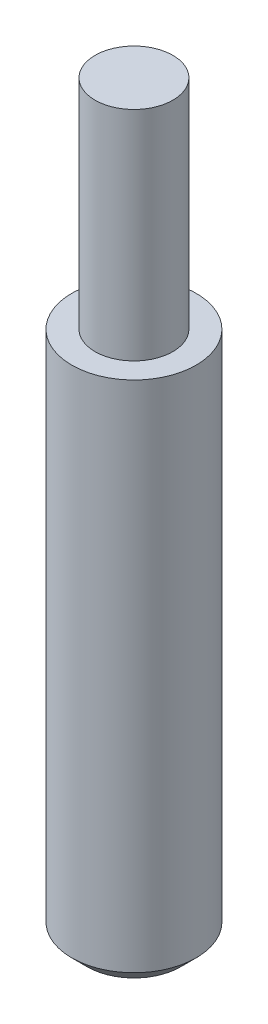
from build123d import *

# Parameters (mm, degrees)
SKETCH1_R           = 101.6
BOSS_EXTRUDE1_DEPTH = 1219.2
SKETCH2_OUTSIDE_W   = 455.722
SKETCH2_OUTSIDE_H   = 455.722
SKETCH2_OUTSIDE_R   = 63.5
CUT_EXTRUDE1_DEPTH  = 355.6
CHAMFER1_SIZE       = 25.4


with BuildPart() as part:
    # Sketch1 → Boss-Extrude1 (new body)
    with BuildSketch(Plane(origin=(0, 0, 0), x_dir=(1, 0, 0), z_dir=(0, 1, 0))):
        with Locations(Location((0, 0, 0), (0, 0, 270))):  # turned: the seam where the file's is
            Circle(SKETCH1_R)
    extrude(amount=BOSS_EXTRUDE1_DEPTH)

    # Sketch2 outside → Cut-Extrude1 (cut)
    with BuildSketch(Plane(origin=(0, 1219.2, 0), x_dir=(1, 0, 0), z_dir=(0, 1, 0))):
        Rectangle(SKETCH2_OUTSIDE_W, SKETCH2_OUTSIDE_H)
        with Locations(Location((0, 0, 0), (0, 0, 270))):  # turned: the seam where the file's is
            Circle(SKETCH2_OUTSIDE_R, mode=Mode.SUBTRACT)
    extrude(amount=-CUT_EXTRUDE1_DEPTH, mode=Mode.SUBTRACT)

    # Chamfer1
    chamfer1_edges = [part.edges().sort_by_distance(p)[0] for p in [
        (0, 0, -101.6),
    ]]
    chamfer(chamfer1_edges, length=CHAMFER1_SIZE)


solid = part.part
